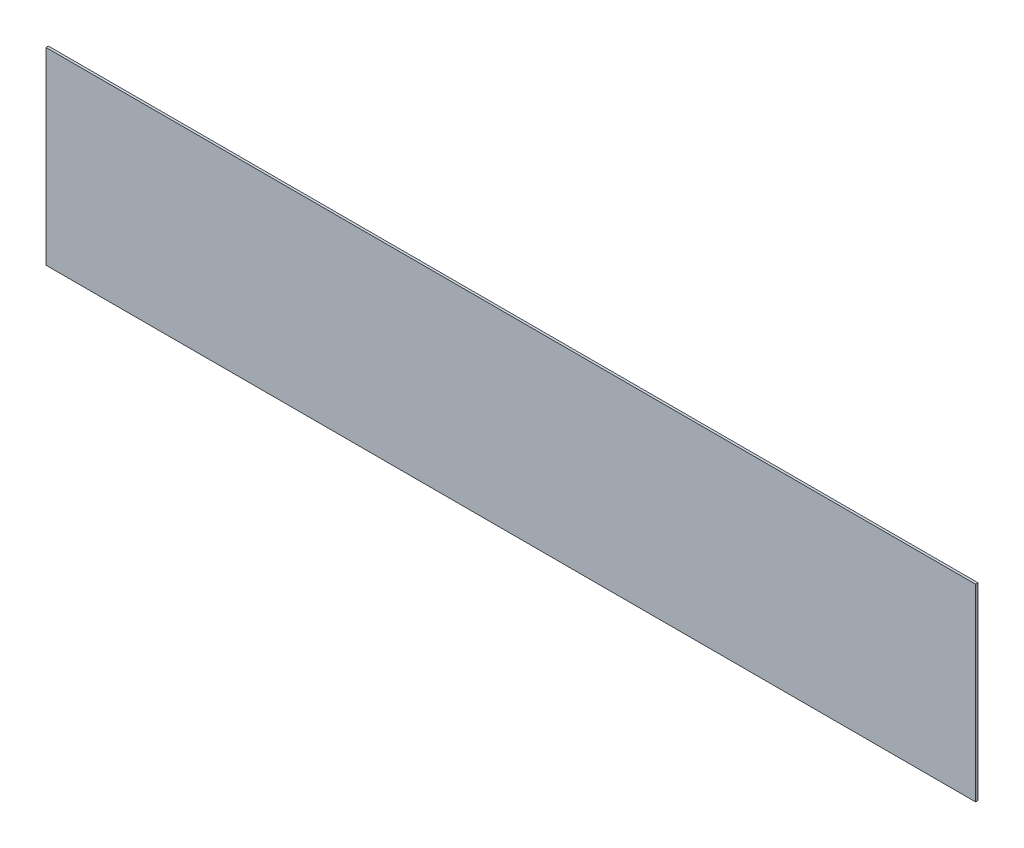
from build123d import *

# Parameters (mm, degrees)
SKETCH1_W           = 609.6
SKETCH1_H           = 123.6726
BOSS_EXTRUDE1_DEPTH = 1.5875


with BuildPart() as part:
    # Sketch1 → Boss-Extrude1 (new body)
    with BuildSketch(Plane.XY):
        with Locations((304.8, 61.8363)):
            Rectangle(SKETCH1_W, SKETCH1_H)
    extrude(amount=BOSS_EXTRUDE1_DEPTH)


solid = part.part
